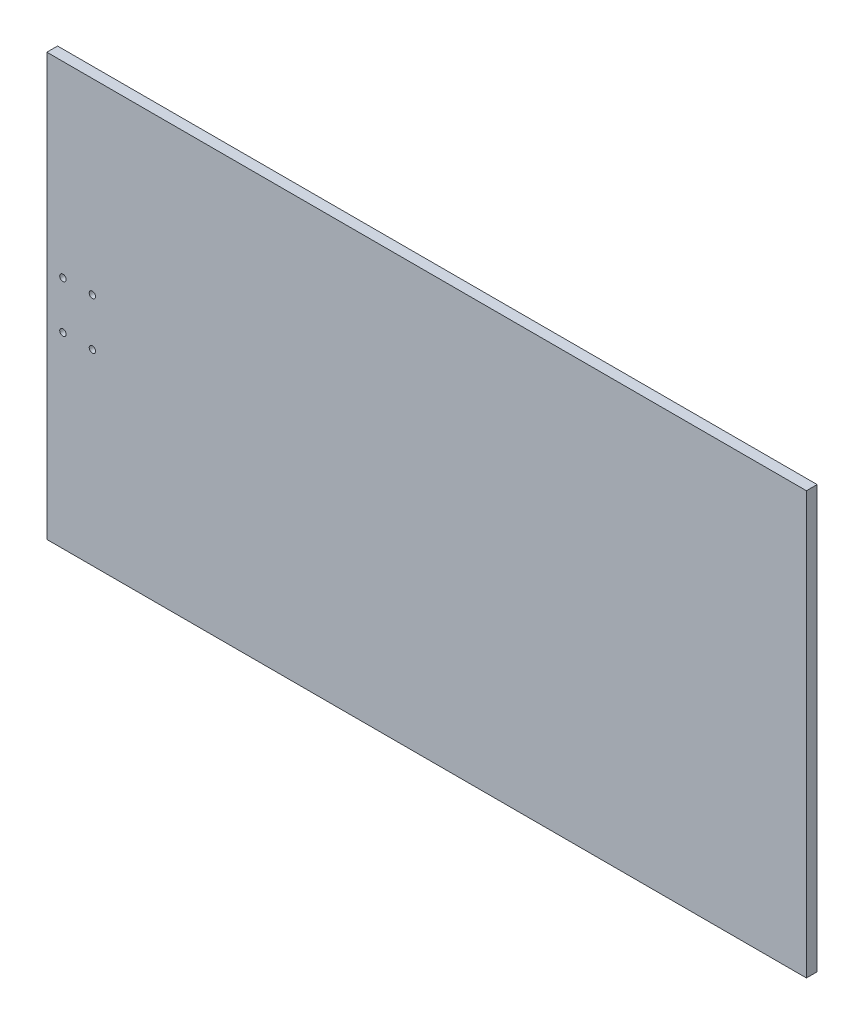
from build123d import *

# Parameters (mm, degrees)
SKETCH1_W             = 450
SKETCH1_H             = 250
BOSS_EXTRUDE1_DEPTH   = 6.35
F_6_CLEARANCE_HOLE2_D = 3.7973


with BuildPart() as part:
    # Sketch1 → Boss-Extrude1 (new body)
    with BuildSketch(Plane.XY):
        Rectangle(SKETCH1_W, SKETCH1_H)
    extrude(amount=BOSS_EXTRUDE1_DEPTH)

    # #6 Clearance Hole2 (through all)
    with Locations(Plane(origin=(0, 0, 0), x_dir=(-1, 0, 0), z_dir=(0, 0, -1))):
        with Locations((198.0125, 14), (215.475, 14), (198.0125, -14), (215.475, -14)):
            Hole(F_6_CLEARANCE_HOLE2_D / 2)


solid = part.part
